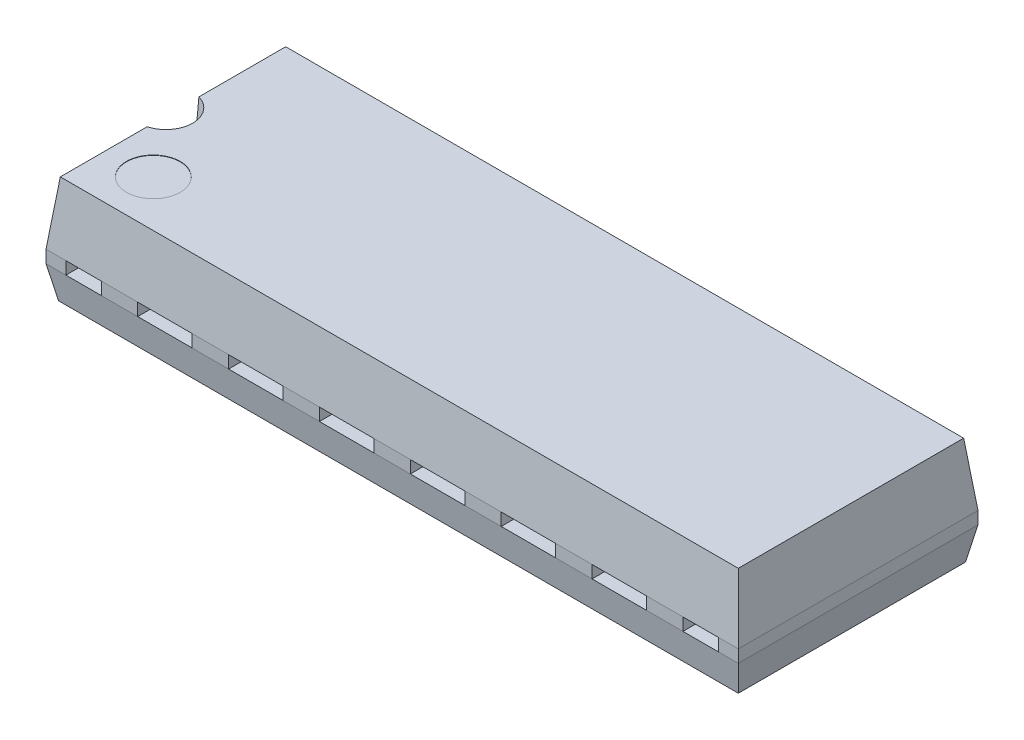
from build123d import *

# Parameters (mm, degrees)
SKETCH2_W      = 18.95
SKETCH2_H      = 6.3
SKETCH1_W      = 19.35
SKETCH1_H      = 6.7
SKETCH3_W      = 19.35
SKETCH3_H      = 6.7
EXTRUDE1_DEPTH = 0.35
SKETCH4_W      = 19.35
SKETCH4_H      = 6.7
SKETCH5_W      = 19
SKETCH5_H      = 6.35
SKETCH7_R      = 0.75
EXTRUDE2_DEPTH = 0.75
SKETCH8_R      = 0.75
EXTRUDE5_DEPTH = 0.01
SKETCH11_W     = 1.524
SKETCH11_H     = 0.35
SKETCH11_W_2   = 0.9906
EXTRUDE3_DEPTH = 1


with BuildPart() as part:
    # Sketch2 → Loft1 section 0
    with BuildSketch(Plane(origin=(0, 1.75, 0), x_dir=(-1, 0, 0), z_dir=(0, 1, 0))):
        Rectangle(SKETCH2_W, SKETCH2_H)
    # Sketch1 → Loft1 section 1
    with BuildSketch(Plane(origin=(0, 0, 0), x_dir=(1, 0, 0), z_dir=(0, 1, 0))):
        Rectangle(SKETCH1_W, SKETCH1_H)
    loft()

    # Sketch3 → Extrude1 (add)
    with BuildSketch(Plane.XZ):
        Rectangle(SKETCH3_W, SKETCH3_H)
    extrude(amount=EXTRUDE1_DEPTH)

    # Sketch4 → Loft2 section 0
    with BuildSketch(Plane.XZ.offset(0.35)):
        Rectangle(SKETCH4_W, SKETCH4_H)
    # Sketch5 → Loft2 section 1
    with BuildSketch(Plane(origin=(0, -1.25, 0), x_dir=(-1, 0, 0), z_dir=(0, 1, 0))):
        Rectangle(SKETCH5_W, SKETCH5_H)
    loft()

    # Sketch7 → Extrude2 (cut)
    with BuildSketch(Plane(origin=(0, 1.75, 0), x_dir=(1, 0, 0), z_dir=(0, 1, 0))):
        with Locations((-9.675, 0)):
            Circle(SKETCH7_R)
    extrude(amount=-EXTRUDE2_DEPTH, mode=Mode.SUBTRACT)

    # Sketch8 → Extrude5 (cut)
    with BuildSketch(Plane(origin=(0, 1.75, 0), x_dir=(1, 0, 0), z_dir=(0, 1, 0))):
        with Locations(Location((-8.175, -1.85, 0), (0, 0, 270))):  # turned: the seam where the file's is
            Circle(SKETCH8_R)
    extrude(amount=-EXTRUDE5_DEPTH, mode=Mode.SUBTRACT)

    # Sketch11 → Extrude3 (cut)
    with BuildSketch(Plane.XY.offset(3.35)):
        with Locations((-3.81, -0.175)):
            Rectangle(SKETCH11_W, SKETCH11_H)
        with Locations((-1.27, -0.175)):
            Rectangle(SKETCH11_W, SKETCH11_H)
        with Locations((1.27, -0.175)):
            Rectangle(SKETCH11_W, SKETCH11_H)
        with Locations((3.80999999, -0.175229628)):
            Rectangle(SKETCH11_W, SKETCH11_H)
        with Locations((6.349999979, -0.175459257)):
            Rectangle(SKETCH11_W, SKETCH11_H)
        with Locations((8.623299969, -0.175688885)):
            Rectangle(SKETCH11_W_2, SKETCH11_H)
        with Locations((-8.6233, -0.175)):
            Rectangle(SKETCH11_W_2, SKETCH11_H)
        with Locations((-6.35, -0.175)):
            Rectangle(SKETCH11_W, SKETCH11_H)
    extrude3 = extrude(amount=-EXTRUDE3_DEPTH, mode=Mode.SUBTRACT)

    # Mirror1: Extrude3 across plane
    add(extrude3.mirror(Plane.XY), mode=Mode.SUBTRACT)


solid = part.part
